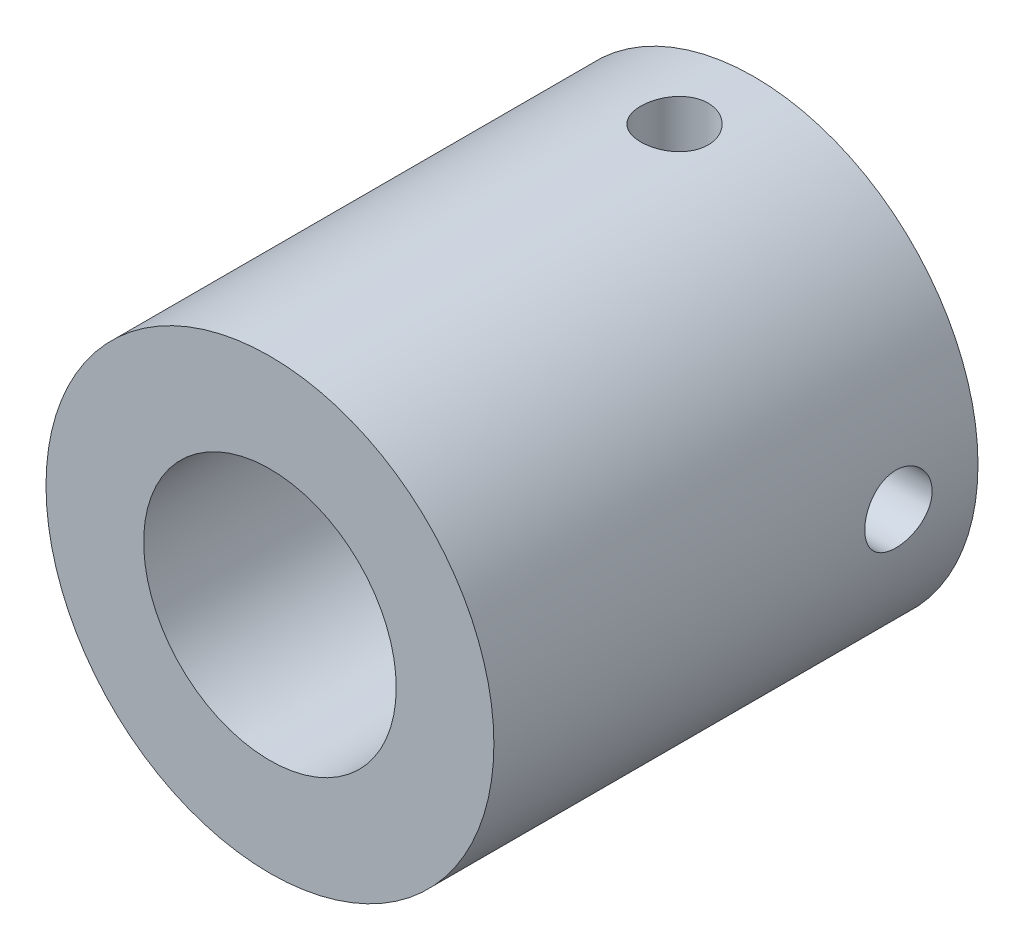
from build123d import *

# Parameters (mm, degrees)
SKETCH1_R           = 16.891
SKETCH1_R_2         = 9.525
BOSS_EXTRUDE1_DEPTH = 36.5125
SKETCH2_R           = 2.54
CUT_EXTRUDE1_DEPTH  = 36.5125
CIRPATTERN1_COUNT   = 4


with BuildPart() as part:
    # Sketch1 → Boss-Extrude1 (new body)
    with BuildSketch(Plane.XY):
        Circle(SKETCH1_R)
        Circle(SKETCH1_R_2, mode=Mode.SUBTRACT)
    extrude(amount=BOSS_EXTRUDE1_DEPTH)

    # Sketch2 → Cut-Extrude1 (cut)
    with BuildSketch(Plane(origin=(16.891, 0, 0), x_dir=(0, 0, -1), z_dir=(1, 0, 0))):
        with Locations((-5.99948, 0)):
            Circle(SKETCH2_R)
    cut_extrude1 = extrude(amount=-CUT_EXTRUDE1_DEPTH, mode=Mode.SUBTRACT)

    # CirPattern1: Cut-Extrude1 ×4 about axis
    cirpattern1_axis = Axis((0, 0, 36.5125), (0, 0, -1))
    for i in range(1, CIRPATTERN1_COUNT):
        add(cut_extrude1.rotate(cirpattern1_axis, i * 360 / CIRPATTERN1_COUNT), mode=Mode.SUBTRACT)


solid = part.part
